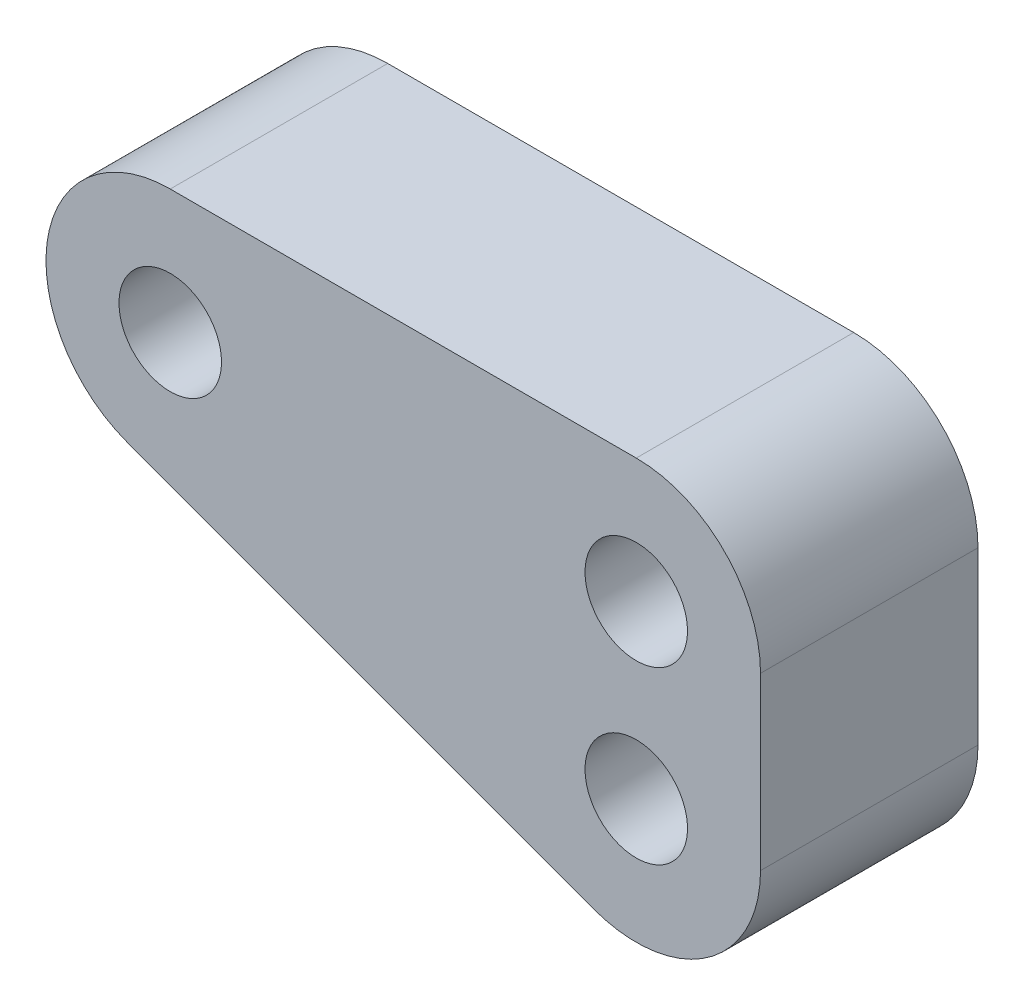
from build123d import *

# Parameters (mm, degrees)
BOSS_EXTRU_1_DEPTH = 7
TROU_TARAUD_M41_D  = 3.3


with BuildPart() as part:
    # Esquisse1 → Boss.-Extru.1 (new body)
    with BuildSketch(Plane.XY):
        with BuildLine():
            Line((-15, 4), (0, 4))
            ThreePointArc((0, 4), (2.828427125, 2.828427125), (4, 0))
            Line((4, 0), (4, -5.5))
            ThreePointArc((4, -5.5), (2.29040669, -8.779334871), (-1.377018597, -9.255505264))
            Line((-1.377018597, -9.255505264), (-16.377018597, -3.755505264))
            ThreePointArc((-16.377018597, -3.755505264), (-18.938402027, 0.699277822), (-15, 4))
        make_face()
    extrude(amount=BOSS_EXTRU_1_DEPTH)

    # Trou taraudé M41 (through all)
    with Locations(Plane(origin=(0, 0, 0), x_dir=(1, 0, 0), z_dir=(0, 0, -1))):
        with Locations((-15, 0), (0, 0), (0, 5.5)):
            Hole(TROU_TARAUD_M41_D / 2)


solid = part.part
